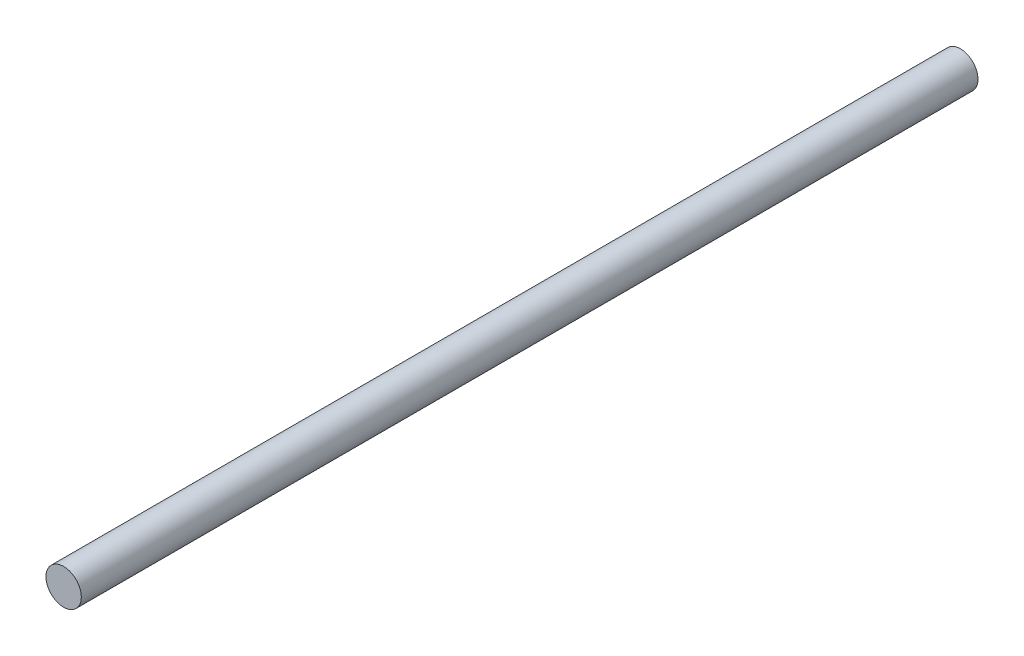
from build123d import *

# Parameters (mm, degrees)
SKETCH_1_R      = 4
EXTRUDE_1_DEPTH = 101.5


with BuildPart() as part:
    # 草图1 → 凸台-拉伸1 (new body, symmetric)
    with BuildSketch(Plane.XY):
        Circle(SKETCH_1_R)
    extrude(amount=EXTRUDE_1_DEPTH, both=True)


solid = part.part
